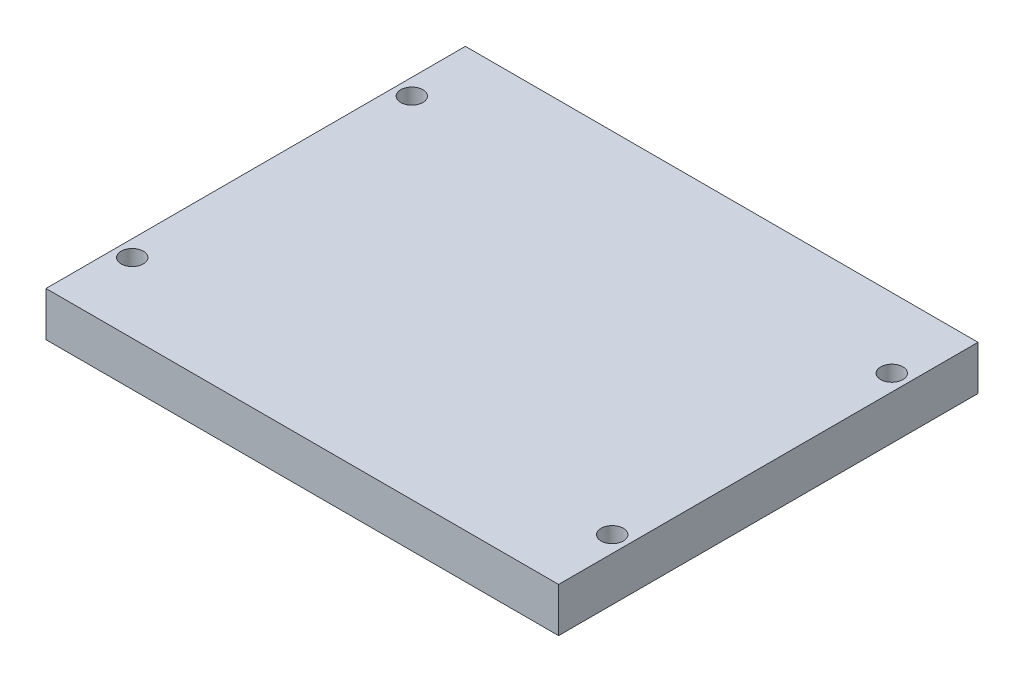
from build123d import *

# Parameters (mm, degrees)
SKETCH1_W           = 110
SKETCH1_H           = 90
BOSS_EXTRUDE1_DEPTH = 9.525
SKETCH2_R           = 2.38125
CUT_EXTRUDE1_DEPTH  = 10.525


with BuildPart() as part:
    # Sketch1 → Boss-Extrude1 (new body)
    with BuildSketch(Plane(origin=(0, 0, 0), x_dir=(1, 0, 0), z_dir=(0, 1, 0))):
        with Locations((55, 45)):
            Rectangle(SKETCH1_W, SKETCH1_H)
    extrude(amount=BOSS_EXTRUDE1_DEPTH)

    # Sketch2 → Cut-Extrude1 (cut, through all)
    with BuildSketch(Plane(origin=(0, 9.525, 0), x_dir=(1, 0, 0), z_dir=(0, 1, 0))):
        with Locations((106.5, 15)):
            Circle(SKETCH2_R)
        with Locations((106.5, 75)):
            Circle(SKETCH2_R)
        with Locations((3.5, 75)):
            Circle(SKETCH2_R)
        with Locations((3.5, 15)):
            Circle(SKETCH2_R)
    extrude(amount=-CUT_EXTRUDE1_DEPTH, mode=Mode.SUBTRACT)


solid = part.part
